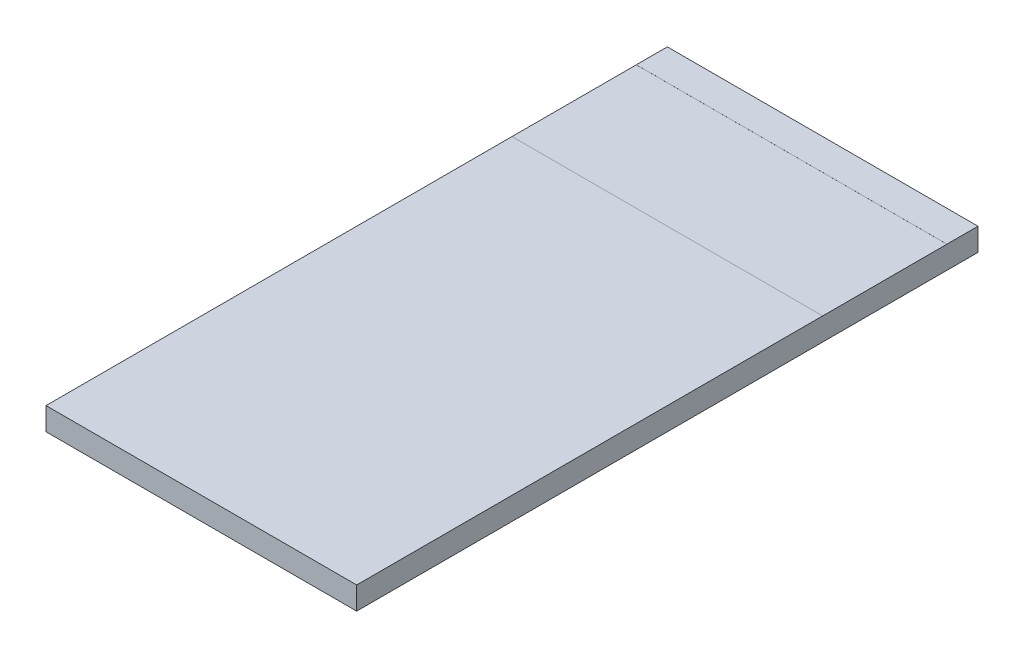
from build123d import *

# Parameters (mm, degrees)
SKETCH1_W           = 1
SKETCH1_H           = 0.072865
BOSS_EXTRUDE1_DEPTH = 2
SKETCH7_W           = 1
SKETCH7_H           = 0.1
SKETCH7_H_2         = 1.5
BOSS_EXTRUDE6_DEPTH = 0.0001
BOSS_EXTRUDE7_START = -0.072865
SKETCH7_2_W         = 1
SKETCH7_2_H         = 0.1
SKETCH7_2_H_2       = 1.5
BOSS_EXTRUDE7_DEPTH = 0.0001


with BuildPart() as part:
    # Sketch1 → Boss-Extrude1 (new body)
    with BuildSketch(Plane.XY):
        with Locations((0.5, 0.0364325)):
            Rectangle(SKETCH1_W, SKETCH1_H)
    extrude(amount=BOSS_EXTRUDE1_DEPTH)

    # Sketch7 → Boss-Extrude6 (add)
    with BuildSketch(Plane(origin=(0, 0.072865, 0), x_dir=(1, 0, 0), z_dir=(0, 1, 0))):
        with Locations((0.5, -0.05)):
            Rectangle(SKETCH7_W, SKETCH7_H)
        with Locations((0.5, -1.25)):
            Rectangle(SKETCH7_W, SKETCH7_H_2)
    extrude(amount=BOSS_EXTRUDE6_DEPTH)

    # Sketch7_2 → Boss-Extrude7 (add)
    with BuildSketch(Plane(origin=(0, 0.072865, 0), x_dir=(1, 0, 0), z_dir=(0, 1, 0)).offset(BOSS_EXTRUDE7_START)):
        with Locations((0.5, -0.05)):
            Rectangle(SKETCH7_2_W, SKETCH7_2_H)
        with Locations((0.5, -1.25)):
            Rectangle(SKETCH7_2_W, SKETCH7_2_H_2)
    extrude(amount=-BOSS_EXTRUDE7_DEPTH)


solid = part.part
